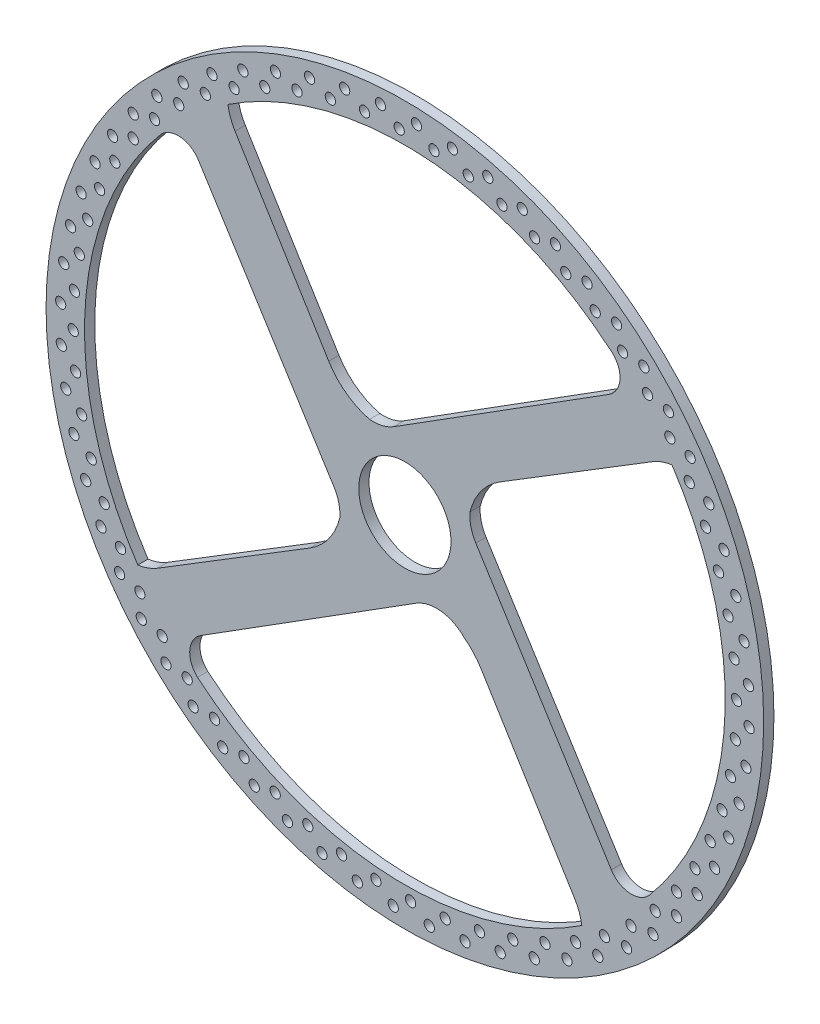
from build123d import *

# Parameters (mm, degrees)
SKETCH1_R               = 70
BOSS_EXTRUDE4_DEPTH     = 1
SKETCH2_R               = 9
CUT_EXTRUDE3_DEPTH      = 2
CUT_EXTRUDE3_DEPTH_BACK = 2
SKETCH7_R               = 1
CUT_EXTRUDE10_DEPTH     = 2
CIRPATTERN3_COUNT       = 60


with BuildPart() as part:
    # Sketch1 → Boss-Extrude4 (new body, symmetric)
    with BuildSketch(Plane.XY):
        Circle(SKETCH1_R)
        with BuildLine():
            Line((-2.165080803, 13.831573487), (39.807063104, 40.273837531))
            ThreePointArc((39.807063104, 40.273837531), (41.958651244, 43.80586549), (40.440634195, 47.652965342))
            ThreePointArc((40.440634195, 47.652965342), (3.706832949, 62.389978278), (-34.513546339, 52.106286752))
            ThreePointArc((-34.513546339, 52.106286752), (-34.02520742, 50.119355564), (-33.138963654, 48.275191138))
            Line((-33.138963654, 48.275191138), (-14.856010945, 18.553154957))
            ThreePointArc((-14.856010945, 18.553154957), (-11.444139621, 14.850827451), (-6.888908787, 12.706540404))
            ThreePointArc((-6.888908787, 12.706540404), (-4.433796823, 12.877734063), (-2.165080803, 13.831573487))
        make_face(mode=Mode.SUBTRACT)
        with BuildLine():
            Line((18.553154957, 14.856010945), (48.275191138, 33.138963654))
            ThreePointArc((48.275191138, 33.138963654), (50.119355564, 34.02520742), (52.106286752, 34.513546339))
            ThreePointArc((52.106286752, 34.513546339), (62.389978278, -3.706832949), (47.652965342, -40.440634195))
            ThreePointArc((47.652965342, -40.440634195), (43.80586549, -41.958651244), (40.273837531, -39.807063104))
            Line((40.273837531, -39.807063104), (13.831573487, 2.165080803))
            ThreePointArc((13.831573487, 2.165080803), (12.877734063, 4.433796823), (12.706540404, 6.888908787))
            ThreePointArc((12.706540404, 6.888908787), (14.850827451, 11.444139621), (18.553154957, 14.856010945))
        make_face(mode=Mode.SUBTRACT)
        with BuildLine():
            Line((14.856010945, -18.553154957), (33.138963654, -48.275191138))
            ThreePointArc((33.138963654, -48.275191138), (34.02520742, -50.119355564), (34.513546339, -52.106286752))
            ThreePointArc((34.513546339, -52.106286752), (-3.706832949, -62.389978278), (-40.440634195, -47.652965342))
            ThreePointArc((-40.440634195, -47.652965342), (-41.958651244, -43.80586549), (-39.807063104, -40.273837531))
            Line((-39.807063104, -40.273837531), (2.165080803, -13.831573487))
            ThreePointArc((2.165080803, -13.831573487), (7.05695818, -12.72438601), (11.558702795, -14.935861491))
            ThreePointArc((11.558702795, -14.935861491), (13.377583175, -16.589340116), (14.856010945, -18.553154957))
        make_face(mode=Mode.SUBTRACT)
        with BuildLine():
            Line((-18.553154957, -14.856010945), (-48.275191138, -33.138963654))
            ThreePointArc((-48.275191138, -33.138963654), (-50.119355564, -34.02520742), (-52.106286752, -34.513546339))
            ThreePointArc((-52.106286752, -34.513546339), (-62.389978278, 3.706832949), (-47.652965342, 40.440634195))
            ThreePointArc((-47.652965342, 40.440634195), (-43.80586549, 41.958651244), (-40.273837531, 39.807063104))
            Line((-40.273837531, 39.807063104), (-13.831573487, -2.165080803))
            ThreePointArc((-13.831573487, -2.165080803), (-12.877734063, -4.433796823), (-12.706540404, -6.888908787))
            ThreePointArc((-12.706540404, -6.888908787), (-14.850827451, -11.444139621), (-18.553154957, -14.856010945))
        make_face(mode=Mode.SUBTRACT)
    extrude(amount=BOSS_EXTRUDE4_DEPTH, both=True)

    # Sketch2 → Cut-Extrude3 (cut, two sides)
    with BuildSketch(Plane.XY) as cut_extrude3_sk:
        Circle(SKETCH2_R)
    extrude(amount=CUT_EXTRUDE3_DEPTH, mode=Mode.SUBTRACT)
    extrude(cut_extrude3_sk.sketch, amount=-CUT_EXTRUDE3_DEPTH_BACK, mode=Mode.SUBTRACT)

    # Sketch7 → Cut-Extrude10 (cut)
    with BuildSketch(Plane.XY.offset(1)):
        with Locations((41.303649487, 52.995644694)):
            Circle(SKETCH7_R)
        with Locations((37.131252915, 52.995644694)):
            Circle(SKETCH7_R)
    cut_extrude10 = extrude(amount=-CUT_EXTRUDE10_DEPTH, mode=Mode.SUBTRACT)

    # CirPattern3: Cut-Extrude10 ×60 about axis
    cirpattern3_axis = Axis((0, 0, 0), (0, 0, 1))
    for i in range(1, CIRPATTERN3_COUNT):
        add(cut_extrude10.rotate(cirpattern3_axis, i * 360 / CIRPATTERN3_COUNT), mode=Mode.SUBTRACT)


solid = part.part
